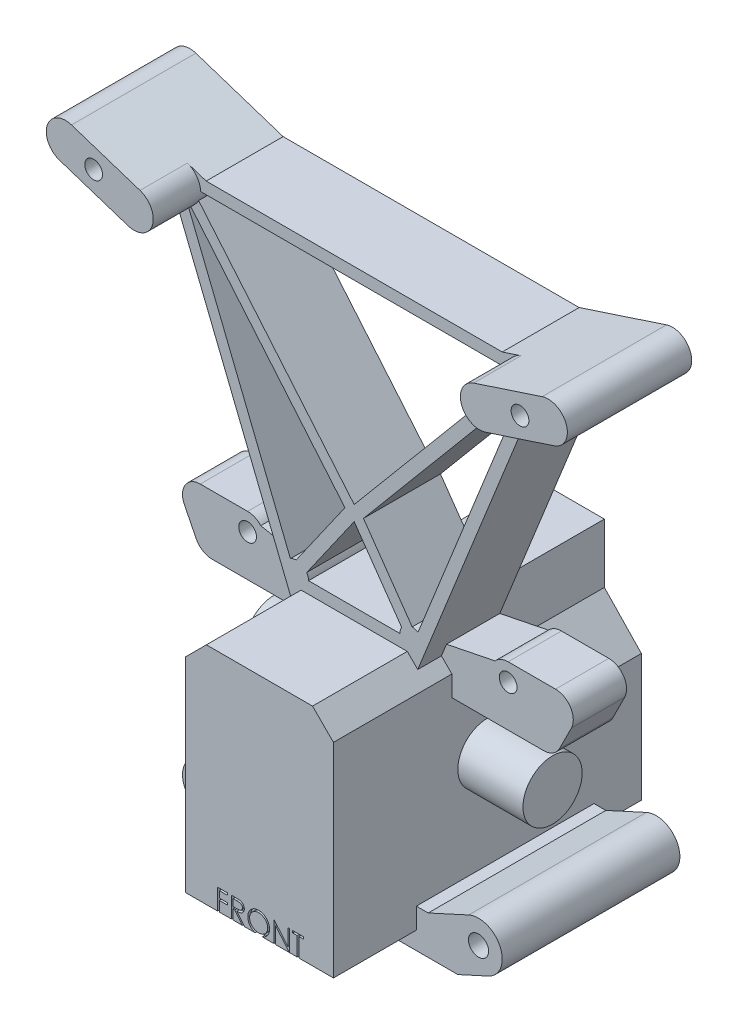
from build123d import *

# Parameters (mm, degrees)
SKETCH1_R                    = 5
DRIVELINE_AXIS_DEPTH         = 23.5
DUMMY_BOSS_DEPTH             = 26
PIN_BASE_DEPTH               = 30
PIN_HOLES_D                  = 3.4
SKETCH8_R                    = 1.5
UPRIGHTS_DEPTH               = 10
UPRIGHTS_DEPTH_BACK          = 3
SKETCH9_R                    = 1.5
SHOCK_MOUNT_DEPTH            = 8
SHOCK_MOUNT_DEPTH_BACK       = 13
SKETCH10_R                   = 1.5
TURNBUCKLE_MOUNTS_DEPTH      = 6
TURNBUCKLE_MOUNTS_DEPTH_BACK = 3
TURNBUCKLE_ROOM_DEPTH        = 1
TURNBUCKLE_ROOM_DEPTH_BACK   = 23
CUT_EXTRUDE1_DEPTH           = 0.5


with BuildPart() as part:
    # Sketch1 → Driveline Axis (new body, symmetric)
    with BuildSketch(Plane(origin=(0, 0, 0), x_dir=(0, 0, -1), z_dir=(1, 0, 0))):
        Circle(SKETCH1_R)
    extrude(amount=DRIVELINE_AXIS_DEPTH, both=True)

    # Sketch2 → Dummy Boss (add, symmetric)
    with BuildSketch(Plane.XY):
        Polygon((-12.5, -20), (-12.5, 14.464466094), (-8.964466094, 18), (8.964466094, 18), (12.5, 14.464466094), (12.5, -20), align=None)
    extrude(amount=DUMMY_BOSS_DEPTH, both=True)

    # Sketch3 → Pin Base (add)
    with BuildSketch(Plane(origin=(0, 0, -18), x_dir=(-1, 0, 0), z_dir=(0, 0, -1))):
        with BuildLine():
            Line((-19.5, -23), (19.5, -23))
            Line((19.5, -23), (24.664120213, -20.637403458))
            ThreePointArc((24.664120213, -20.637403458), (26.637403458, -15.335879787), (21.335879787, -13.362596542))
            Line((21.335879787, -13.362596542), (14.5, -16.490026826))
            Line((14.5, -16.490026826), (12.5, -16.490026826))
            Line((12.5, -16.490026826), (12.5, -20))
            Line((12.5, -20), (-12.5, -20))
            Line((-12.5, -20), (-12.5, -16.490026826))
            Line((-12.5, -16.490026826), (-14.5, -16.490026826))
            Line((-14.5, -16.490026826), (-21.335879787, -13.362596542))
            ThreePointArc((-21.335879787, -13.362596542), (-26.637403458, -15.335879787), (-24.664120213, -20.637403458))
            Line((-24.664120213, -20.637403458), (-19.5, -23))
        make_face()
    extrude(amount=-PIN_BASE_DEPTH)

    # Pin Holes (through all)
    with Locations(Plane(origin=(0, 0, -18), x_dir=(-1, 0, 0), z_dir=(0, 0, -1))):
        with Locations((-23, -17), (23, -17)):
            Hole(PIN_HOLES_D / 2)

    # Sketch8 → Uprights (add, two sides)
    with BuildSketch(Plane.XY) as uprights_sk:
        with BuildLine():
            Line((-10.732233047, 16.232233047), (-30.201724718, 64.676412332))
            Line((-30.201724718, 64.676412332), (-41.764151193, 68.471255083))
            ThreePointArc((-41.764151193, 68.471255083), (-43.838613984, 72.572669977), (-39.73719909, 74.647132768))
            Line((-39.73719909, 74.647132768), (-25, 69.810314713))
            Line((-25, 69.810314713), (25, 69.810314713))
            Line((25, 69.810314713), (39.73719909, 74.647132768))
            ThreePointArc((39.73719909, 74.647132768), (43.838613984, 72.572669977), (41.764151193, 68.471255083))
            Line((41.764151193, 68.471255083), (30.201724718, 64.676412332))
            Line((30.201724718, 64.676412332), (10.732233047, 16.232233047))
            Line((10.732233047, 16.232233047), (8.964466094, 18))
            Line((8.964466094, 18), (-8.964466094, 18))
            Line((-8.964466094, 18), (-10.732233047, 16.232233047))
        make_face()
        with Locations((-36, 70)):
            Circle(SKETCH8_R, mode=Mode.SUBTRACT)
        with Locations((36, 70)):
            Circle(SKETCH8_R, mode=Mode.SUBTRACT)
        with BuildLine():
            Line((9.794860183, 21.998383544), (1.564311135, 33.752825762))
            Line((1.564311135, 33.752825762), (28.537091438, 65.897733589))
            Line((28.537091438, 65.897733589), (10.772988077, 21.696918151))
            ThreePointArc((10.772988077, 21.696918151), (10.30353553, 21.911281559), (9.794860183, 21.998383544))
        make_face(mode=Mode.SUBTRACT)
        with BuildLine():
            Line((7.714466094, 20), (-7.714466094, 20))
            ThreePointArc((-7.714466094, 20), (-7.790978186, 20.547899872), (-8.014660363, 21.053878777))
            Line((-8.014660363, 21.053878777), (0, 32.5))
            Line((0, 32.5), (8.014660363, 21.053878777))
            ThreePointArc((8.014660363, 21.053878777), (7.790978186, 20.547899872), (7.714466094, 20))
        make_face(mode=Mode.SUBTRACT)
        with BuildLine():
            Line((-10.772988077, 21.696918151), (-28.537091438, 65.897733589))
            Line((-28.537091438, 65.897733589), (-1.564311135, 33.752825762))
            Line((-1.564311135, 33.752825762), (-9.794860183, 21.998383544))
            ThreePointArc((-9.794860183, 21.998383544), (-10.30353553, 21.911281559), (-10.772988077, 21.696918151))
        make_face(mode=Mode.SUBTRACT)
        Polygon((-27.531122974, 67.810314713), (0, 35), (27.531122974, 67.810314713), align=None, mode=Mode.SUBTRACT)
    extrude(amount=UPRIGHTS_DEPTH)
    extrude(uprights_sk.sketch, amount=-UPRIGHTS_DEPTH_BACK)

    # Sketch9 → Shock Mount (add, two sides)
    with BuildSketch(Plane.XY.offset(10)) as shock_mount_sk:
        with BuildLine():
            Line((-30.201724718, 64.676412332), (-41.764151193, 68.471255083))
            ThreePointArc((-41.764151193, 68.471255083), (-43.838613984, 72.572669977), (-39.73719909, 74.647132768))
            Line((-39.73719909, 74.647132768), (-28.174772615, 70.852290017))
            ThreePointArc((-28.174772615, 70.852290017), (-26.100309824, 66.750875123), (-30.201724718, 64.676412332))
        make_face()
        with Locations((-36, 70)):
            Circle(SKETCH9_R, mode=Mode.SUBTRACT)
        with BuildLine():
            Line((28.174772615, 70.852290017), (39.73719909, 74.647132768))
            ThreePointArc((39.73719909, 74.647132768), (43.838613984, 72.572669977), (41.764151193, 68.471255083))
            Line((41.764151193, 68.471255083), (30.201724718, 64.676412332))
            ThreePointArc((30.201724718, 64.676412332), (26.100309824, 66.750875123), (28.174772615, 70.852290017))
        make_face()
        with Locations((36, 70)):
            Circle(SKETCH9_R, mode=Mode.SUBTRACT)
    extrude(amount=SHOCK_MOUNT_DEPTH)
    extrude(shock_mount_sk.sketch, amount=-SHOCK_MOUNT_DEPTH_BACK)

    # Sketch10 → Turnbuckle Mounts (add, two sides)
    with BuildSketch(Plane.XY) as turnbuckle_mounts_sk:
        with BuildLine():
            Line((28, 11), (9.803335309, 11))
            Line((9.803335309, 11), (9.803335309, 18))
            Line((9.803335309, 18), (19.782196277, 20.020234305))
            ThreePointArc((19.782196277, 20.020234305), (20.787709382, 20.744148585), (22, 21))
            Line((22, 21), (30, 21))
            ThreePointArc((30, 21), (32.551952425, 19.577193336), (32.683281573, 16.658359214))
            Line((32.683281573, 16.658359214), (30.683281573, 12.658359214))
            ThreePointArc((30.683281573, 12.658359214), (29.577193336, 11.448047575), (28, 11))
        make_face()
        with Locations((22, 18)):
            Circle(SKETCH10_R, mode=Mode.SUBTRACT)
        with BuildLine():
            Line((-9.803335309, 18), (-19.782196277, 20.020234305))
            ThreePointArc((-19.782196277, 20.020234305), (-20.787709382, 20.744148585), (-22, 21))
            Line((-22, 21), (-30, 21))
            ThreePointArc((-30, 21), (-32.551952425, 19.577193336), (-32.683281573, 16.658359214))
            Line((-32.683281573, 16.658359214), (-30.683281573, 12.658359214))
            ThreePointArc((-30.683281573, 12.658359214), (-29.577193336, 11.448047575), (-28, 11))
            Line((-28, 11), (-9.803335309, 11))
            Line((-9.803335309, 11), (-9.803335309, 18))
        make_face()
        with Locations((-22, 18)):
            Circle(SKETCH10_R, mode=Mode.SUBTRACT)
    extrude(amount=TURNBUCKLE_MOUNTS_DEPTH)
    extrude(turnbuckle_mounts_sk.sketch, amount=-TURNBUCKLE_MOUNTS_DEPTH_BACK)

    # Sketch11 → Turnbuckle Room (cut, two sides)
    with BuildSketch(Plane(origin=(0, 0, -26), x_dir=(-1, 0, 0), z_dir=(0, 0, -1))) as turnbuckle_room_sk:
        Polygon((8.964466094, 18), (5.75, 18), (5.75, 8), (12.5, 1.544903812), (12.5, 14.464466094), align=None)
        Polygon((-12.5, 14.464466094), (-12.5, 1.464466094), (-6.25, 8), (-6.25, 18), (-8.964466094, 18), align=None)
    extrude(amount=TURNBUCKLE_ROOM_DEPTH, mode=Mode.SUBTRACT)
    extrude(turnbuckle_room_sk.sketch, amount=-TURNBUCKLE_ROOM_DEPTH_BACK, mode=Mode.SUBTRACT)

    # Sketch12 → Cut-Extrude1 (cut)
    with BuildSketch(Plane.XY.offset(26)):
        Polygon((-7.08974359, -16.5), (-5.384615385, -16.5), (-5.384615385, -16.858974359), (-6.775641026, -16.858974359), (-6.775641026, -17.935897436), (-5.384615385, -17.935897436), (-5.384615385, -18.294871795), (-6.775641026, -18.294871795), (-6.775641026, -20), (-7.08974359, -20), align=None)
        with BuildLine():
            Line((-4.756410256, -16.5), (-4.055989583, -16.5))
            add(Edge.make_bspline(
                [(-4.055989583, -16.5), (-4.009248455, -16.500155586), (-3.91950031, -16.500454328), (-3.79092704, -16.502120091), (-3.674099943, -16.506894447), (-3.569080104, -16.51100303), (-3.475869449, -16.518494972), (-3.394182158, -16.525655619), (-3.324394461, -16.53502928), (-3.282148609, -16.543734703), (-3.263020833, -16.547676282)],
                knots=[0, 0, 0, 0, 0.000140226, 0.00026925, 0.000385712, 0.000490995, 0.000584507, 0.000666202, 0.000736998, 0.000795574, 0.000795574, 0.000795574, 0.000795574], degree=3))
            add(Edge.make_bspline(
                [(-3.263020833, -16.547676282), (-3.237414209, -16.554003047), (-3.18674722, -16.566521611), (-3.113797154, -16.592981212), (-3.04428283, -16.623600837), (-2.978493005, -16.659564557), (-2.916757214, -16.701139337), (-2.858438903, -16.747607459), (-2.80327344, -16.798714665), (-2.75349181, -16.855749506), (-2.706552758, -16.915586016), (-2.666964132, -16.980289773), (-2.632837652, -17.0479513), (-2.605667135, -17.119258718), (-2.583789161, -17.19352049), (-2.568362922, -17.271409287), (-2.559111734, -17.352570262), (-2.558169879, -17.40792817), (-2.557692308, -17.435997596)],
                knots=[0, 0, 0, 0, 7.9081e-05, 0.000156475, 0.000232432, 0.000306798, 0.00038108, 0.000455429, 0.000530331, 0.000606314, 0.000682321, 0.000758201, 0.000833453, 0.000909362, 0.000986794, 0.001065445, 0.001147284, 0.001231465, 0.001231465, 0.001231465, 0.001231465], degree=3))
            add(Edge.make_bspline(
                [(-2.557692308, -17.435997596), (-2.559161306, -17.482632701), (-2.562027702, -17.573629869), (-2.588752805, -17.70569075), (-2.632529325, -17.828880065), (-2.692852614, -17.943042703), (-2.76967209, -18.045953348), (-2.861996881, -18.136343803), (-2.969878492, -18.211983716), (-3.070307808, -18.264436521), (-3.159022008, -18.298029429), (-3.232055321, -18.321665788), (-3.311722298, -18.339927753), (-3.397259633, -18.356287885), (-3.489023288, -18.36863958), (-3.586793328, -18.377686174), (-3.690639479, -18.383340223), (-3.761978549, -18.384182228), (-3.798677885, -18.384615385)],
                knots=[0, 0, 0, 0, 0.000139777, 0.000272741, 0.000402249, 0.000530843, 0.000658588, 0.000786009, 0.000916741, 0.001052522, 0.001124656, 0.001201155, 0.001282612, 0.001369656, 0.001462366, 0.001560247, 0.001664165, 0.001774261, 0.001774261, 0.001774261, 0.001774261], degree=3))
            Line((-3.798677885, -18.384615385), (-2.512820513, -20))
            Line((-2.512820513, -20), (-2.901241987, -20))
            Line((-2.901241987, -20), (-4.187099359, -18.384615385))
            Line((-4.187099359, -18.384615385), (-4.442307692, -18.384615385))
            Line((-4.442307692, -18.384615385), (-4.442307692, -20))
            Line((-4.442307692, -20), (-4.756410256, -20))
            Line((-4.756410256, -20), (-4.756410256, -16.5))
        make_face()
        with BuildLine():
            Line((-4.442307692, -16.858974359), (-4.442307692, -18.025641026))
            Line((-4.442307692, -18.025641026), (-3.801482372, -18.030548878))
            add(Edge.make_bspline(
                [(-3.801482372, -18.030548878), (-3.771562333, -18.030562115), (-3.713568776, -18.030587771), (-3.629668111, -18.026593995), (-3.551547999, -18.022050677), (-3.479507247, -18.015101331), (-3.413513672, -18.00614526), (-3.353600259, -17.994942275), (-3.299669207, -17.981890213), (-3.236770668, -17.961688587), (-3.166534137, -17.929682569), (-3.090202677, -17.88311707), (-3.025200339, -17.824547951), (-2.970282477, -17.757574495), (-2.926153045, -17.683938246), (-2.895040991, -17.604521877), (-2.875298549, -17.521330279), (-2.872970003, -17.464152171), (-2.871794872, -17.435296474)],
                knots=[0, 0, 0, 0, 8.9746e-05, 0.000173954, 0.000251933, 0.000324488, 0.000391021, 0.000451663, 0.000507268, 0.000557378, 0.000649639, 0.000738152, 0.000824558, 0.000910739, 0.000997194, 0.001080909, 0.00116578, 0.001252248, 0.001252248, 0.001252248, 0.001252248], degree=3))
            add(Edge.make_bspline(
                [(-2.871794872, -17.435296474), (-2.872996993, -17.407149901), (-2.875379158, -17.351373662), (-2.894827927, -17.269717752), (-2.927717308, -17.192650802), (-2.972039546, -17.120486317), (-3.026038701, -17.054980581), (-3.089356514, -16.998933428), (-3.160261709, -16.952683963), (-3.226532907, -16.923129582), (-3.28576712, -16.905009729), (-3.33719678, -16.892258565), (-3.395308257, -16.882014096), (-3.460383716, -16.873806036), (-3.532145347, -16.866751091), (-3.610955998, -16.861999313), (-3.696292778, -16.859185449), (-3.755439709, -16.85904636), (-3.786057692, -16.858974359)],
                knots=[0, 0, 0, 0, 8.4371e-05, 0.000167192, 0.000250141, 0.000334794, 0.000420435, 0.000503871, 0.000587493, 0.000673488, 0.0007205, 0.000773215, 0.000832351, 0.0008974, 0.000969955, 0.001048634, 0.001134217, 0.001226067, 0.001226067, 0.001226067, 0.001226067], degree=3))
            Line((-3.786057692, -16.858974359), (-4.442307692, -16.858974359))
        make_face(mode=Mode.SUBTRACT)
        with BuildLine():
            add(Edge.make_bspline(
                [(-0.157051282, -16.41025641), (-0.092243176, -16.41189789), (0.035045291, -16.415121891), (0.222120189, -16.439800994), (0.400715284, -16.482496384), (0.572285423, -16.539359367), (0.734778399, -16.615213752), (0.889417292, -16.7068989), (1.035834166, -16.815375359), (1.172055547, -16.939804586), (1.296712497, -17.07518804), (1.406538384, -17.21966595), (1.498580677, -17.372364752), (1.574166464, -17.532825583), (1.633465074, -17.700685551), (1.674384118, -17.876839554), (1.700522268, -18.060146244), (1.703578045, -18.185173108), (1.705128205, -18.248597756)],
                knots=[0, 0, 0, 0, 0.000194393, 0.000381804, 0.00056479, 0.000744601, 0.000923091, 0.001101652, 0.001283106, 0.001468738, 0.001654324, 0.001834514, 0.002012231, 0.002188181, 0.002365797, 0.002545211, 0.002729936, 0.002920126, 0.002920126, 0.002920126, 0.002920126], degree=3))
            add(Edge.make_bspline(
                [(1.705128205, -18.248597756), (1.703578273, -18.311555203), (1.700523176, -18.435651623), (1.674354399, -18.617795067), (1.633313399, -18.792885764), (1.574717132, -18.960631417), (1.499491654, -19.12120898), (1.406836483, -19.274195934), (1.297695272, -19.419642433), (1.173488421, -19.555955098), (1.038087379, -19.680952569), (0.892857112, -19.789871444), (0.741063792, -19.883595569), (0.580754084, -19.958379243), (0.414054047, -20.018151163), (0.239471724, -20.058903793), (0.05782517, -20.085190837), (-0.066045834, -20.088209353), (-0.12900641, -20.08974359)],
                knots=[0, 0, 0, 0, 0.000188789, 0.000372126, 0.000550857, 0.00072758, 0.000904164, 0.001081881, 0.001263191, 0.001448823, 0.00163441, 0.001815159, 0.001992641, 0.002168591, 0.002344885, 0.002522934, 0.002705576, 0.002894365, 0.002894365, 0.002894365, 0.002894365], degree=3))
            add(Edge.make_bspline(
                [(-0.12900641, -20.08974359), (-0.192430729, -20.088194203), (-0.317456945, -20.085139949), (-0.500993981, -20.058958544), (-0.677271724, -20.01801724), (-0.845786076, -19.959507804), (-1.006631005, -19.883890573), (-1.160121088, -19.791686194), (-1.305640235, -19.682279053), (-1.441981982, -19.558112479), (-1.56673118, -19.422940927), (-1.675490556, -19.278106671), (-1.767715669, -19.126451215), (-1.843079001, -18.967553691), (-1.902743461, -18.802182248), (-1.943448279, -18.629233771), (-1.969784231, -18.449694265), (-1.972819077, -18.327451366), (-1.974358974, -18.265424679)],
                knots=[0, 0, 0, 0, 0.00019019, 0.000374915, 0.000555011, 0.000732396, 0.00090898, 0.001087298, 0.001268608, 0.00145424, 0.001639827, 0.001819595, 0.001996712, 0.002171394, 0.002346367, 0.002523053, 0.002703612, 0.002889599, 0.002889599, 0.002889599, 0.002889599], degree=3))
            add(Edge.make_bspline(
                [(-1.974358974, -18.265424679), (-1.973824339, -18.22379201), (-1.972761813, -18.141051887), (-1.95997012, -18.018185287), (-1.941408419, -17.897294629), (-1.914806506, -17.778723681), (-1.880014839, -17.662762696), (-1.838962812, -17.548611933), (-1.788822967, -17.43742821), (-1.732142319, -17.328684818), (-1.66888051, -17.224076912), (-1.599004761, -17.125197329), (-1.524969393, -17.031216332), (-1.443805999, -16.944569328), (-1.358189554, -16.862735672), (-1.266731176, -16.786972955), (-1.169988931, -16.716598004), (-1.067546551, -16.653177663), (-0.961928277, -16.595818528), (-0.853051499, -16.546596677), (-0.742394927, -16.504350616), (-0.629440279, -16.470109791), (-0.514487507, -16.443077755), (-0.397285723, -16.424670401), (-0.277928296, -16.411846083), (-0.197516978, -16.410788581), (-0.157051282, -16.41025641)],
                knots=[0, 0, 0, 0, 0.000124849, 0.000248123, 0.000370193, 0.00049164, 0.000612319, 0.000733199, 0.000855287, 0.000977905, 0.001100913, 0.001221706, 0.001340948, 0.001459521, 0.001577551, 0.001696047, 0.001815534, 0.001936153, 0.002057243, 0.002175846, 0.002294342, 0.002412335, 0.002529682, 0.00264829, 0.002768075, 0.00288942, 0.00288942, 0.00288942, 0.00288942], degree=3))
        make_face()
        with BuildLine():
            add(Edge.make_bspline(
                [(-0.141626603, -16.769230769), (-0.174841236, -16.769635659), (-0.240952969, -16.770441569), (-0.339237505, -16.781057285), (-0.436229439, -16.796187174), (-0.531948801, -16.817768695), (-0.625995091, -16.847172747), (-0.719244932, -16.881013655), (-0.810847986, -16.922234746), (-0.900501844, -16.96880745), (-0.987416919, -17.020356371), (-1.06942962, -17.077328138), (-1.146752264, -17.138386693), (-1.219195531, -17.20367453), (-1.286546703, -17.273524132), (-1.350131404, -17.346876568), (-1.407400986, -17.425828459), (-1.459886563, -17.508238866), (-1.506854403, -17.594000447), (-1.548619758, -17.682210309), (-1.582783767, -17.773587996), (-1.610646143, -17.867142154), (-1.633745954, -17.962724613), (-1.648379878, -18.061060462), (-1.659112237, -18.161655574), (-1.659872083, -18.229637428), (-1.66025641, -18.264022436)],
                knots=[0, 0, 0, 0, 9.9599e-05, 0.000198245, 0.000296222, 0.00039402, 0.00049227, 0.000591646, 0.000691452, 0.000793368, 0.000894612, 0.000994383, 0.001092713, 0.00119001, 0.001286696, 0.001383657, 0.001480979, 0.001579008, 0.001676595, 0.001774142, 0.001871547, 0.001968922, 0.002066879, 0.00216624, 0.00226698, 0.002370083, 0.002370083, 0.002370083, 0.002370083], degree=3))
            add(Edge.make_bspline(
                [(-1.66025641, -18.264022436), (-1.658981548, -18.314584657), (-1.6564735, -18.414056187), (-1.63451593, -18.559824331), (-1.600693956, -18.699912617), (-1.550836589, -18.833554526), (-1.488485975, -18.961898809), (-1.411459084, -19.083806914), (-1.320199999, -19.199311788), (-1.216536472, -19.307607057), (-1.103213766, -19.406452862), (-0.982881036, -19.49321627), (-0.856827428, -19.56662652), (-0.724724226, -19.626431592), (-0.587276687, -19.67382133), (-0.443599136, -19.706299961), (-0.294648676, -19.727675417), (-0.193118021, -19.729728173), (-0.141626603, -19.730769231)],
                knots=[0, 0, 0, 0, 0.000151605, 0.000298253, 0.000441263, 0.000583229, 0.000725274, 0.000868635, 0.001014928, 0.001166177, 0.001317744, 0.00146543, 0.001610576, 0.001754594, 0.001899821, 0.002045914, 0.002195936, 0.002350312, 0.002350312, 0.002350312, 0.002350312], degree=3))
            add(Edge.make_bspline(
                [(-0.141626603, -19.730769231), (-0.107017101, -19.730293726), (-0.038376065, -19.729350658), (0.063719458, -19.719851982), (0.16397567, -19.704620112), (0.262251949, -19.682689457), (0.358436761, -19.65524225), (0.452931564, -19.622634522), (0.544729854, -19.581953318), (0.634989692, -19.537005367), (0.721385934, -19.485765209), (0.803861466, -19.43072706), (0.880337446, -19.369758439), (0.952726517, -19.305440626), (1.020354206, -19.236476779), (1.08276319, -19.162956557), (1.139743323, -19.0844159), (1.192208969, -19.002130494), (1.239012232, -18.916134241), (1.279791331, -18.827604563), (1.314387447, -18.736759454), (1.342315952, -18.643467882), (1.364201413, -18.547907034), (1.379281333, -18.449948955), (1.389829772, -18.349789613), (1.390624849, -18.282045757), (1.391025641, -18.247896635)],
                knots=[0, 0, 0, 0, 0.000103804, 0.000205874, 0.000307314, 0.000407849, 0.000507719, 0.000607281, 0.000707445, 0.000808723, 0.000909609, 0.001008589, 0.001105934, 0.001202762, 0.001298946, 0.001395452, 0.001491794, 0.001589823, 0.001688026, 0.001785277, 0.001882027, 0.001979402, 0.0020772, 0.002175869, 0.002276609, 0.002379011, 0.002379011, 0.002379011, 0.002379011], degree=3))
            add(Edge.make_bspline(
                [(1.391025641, -18.247896635), (1.390624528, -18.21398113), (1.389828847, -18.14670348), (1.379286372, -18.047242662), (1.364185482, -17.94998945), (1.342422774, -17.855325647), (1.31437262, -17.763227122), (1.279785289, -17.673780375), (1.23899999, -17.586652179), (1.192191766, -17.502057882), (1.139575942, -17.420883145), (1.082081699, -17.343280732), (1.018716351, -17.270707991), (0.951290326, -17.201373297), (0.87811944, -17.136755407), (0.799535146, -17.076832886), (0.716491469, -17.020159612), (0.628564233, -16.96903405), (0.537820279, -16.921819818), (0.444706321, -16.881368814), (0.350277222, -16.846996695), (0.254773109, -16.81767973), (0.157390131, -16.7962717), (0.058786302, -16.78104365), (-0.040901956, -16.770445264), (-0.107945176, -16.769636886), (-0.141626603, -16.769230769)],
                knots=[0, 0, 0, 0, 0.000101701, 0.000201743, 0.00029972, 0.000396835, 0.000492868, 0.000588308, 0.000684288, 0.000781261, 0.000878109, 0.000974304, 0.001070733, 0.001166917, 0.001264269, 0.001363274, 0.001463228, 0.001565678, 0.001668217, 0.001769947, 0.001869982, 0.001969573, 0.002069423, 0.002168785, 0.002268827, 0.002369827, 0.002369827, 0.002369827, 0.002369827], degree=3))
        make_face(mode=Mode.SUBTRACT)
        Polygon((2.423076923, -20), (2.423076923, -16.5), (2.488982372, -16.5), (4.801282051, -19.254707532), (4.801282051, -16.5), (5.115384615, -16.5), (5.115384615, -20), (5.043870192, -20), (2.737179487, -17.251602564), (2.737179487, -20), align=None)
        Polygon((5.608974359, -16.858974359), (5.608974359, -16.5), (7.448717949, -16.5), (7.448717949, -16.858974359), (6.685897436, -16.858974359), (6.685897436, -20), (6.371794872, -20), (6.371794872, -16.858974359), align=None)
    extrude(amount=-CUT_EXTRUDE1_DEPTH, mode=Mode.SUBTRACT)


solid = part.part
